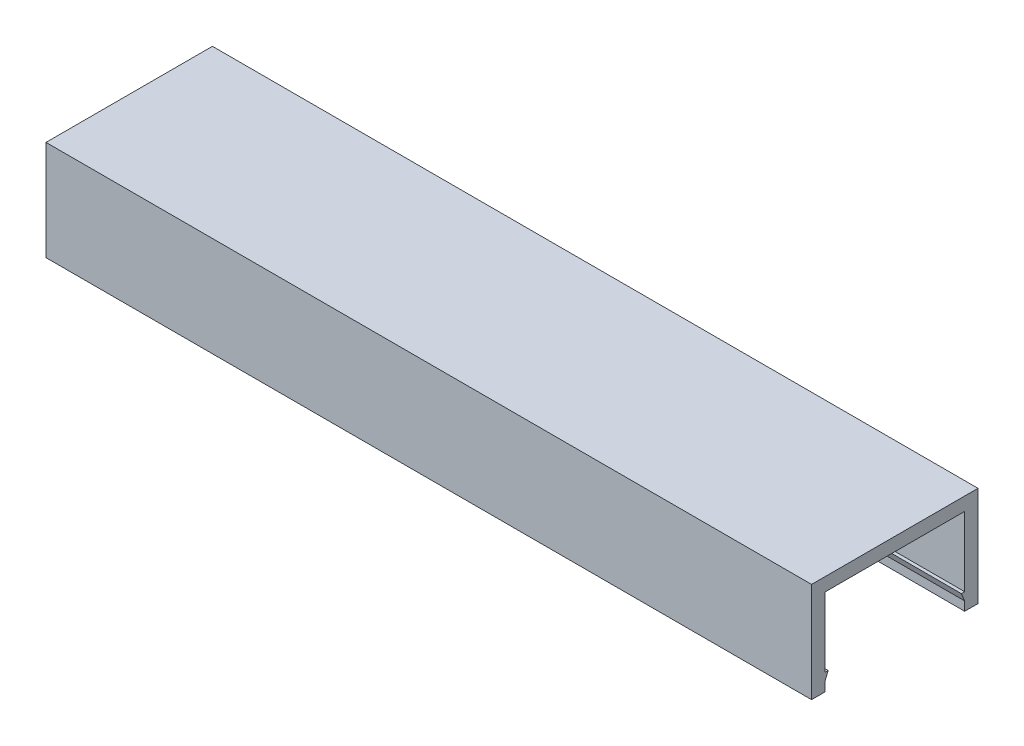
from build123d import *

# Parameters (mm, degrees)
CROQUIS1_W              = 115
CROQUIS1_H              = 20.7
CROQUIS1_H_2            = 2.15
SALIENTE_EXTRUIR1_DEPTH = 15
CROQUIS2_W              = 21
CROQUIS2_H              = 13
CORTAR_EXTRUIR1_DEPTH   = 230
SALIENTE_EXTRUIR4_DEPTH = 115


with BuildPart() as part:
    # Croquis1 → Saliente-Extruir1 (new body)
    with BuildSketch(Plane(origin=(0, 0, 0), x_dir=(1, 0, 0), z_dir=(0, 1, 0))):
        Rectangle(CROQUIS1_W, CROQUIS1_H)
        with Locations((0, 11.425)):
            Rectangle(CROQUIS1_W, CROQUIS1_H_2)
        with Locations((0, -11.425)):
            Rectangle(CROQUIS1_W, CROQUIS1_H_2)
    extrude(amount=SALIENTE_EXTRUIR1_DEPTH)

    # Croquis2 → Cortar-Extruir1 (cut)
    with BuildSketch(Plane.ZY.offset(57.5)):
        with Locations((0, 6.5)):
            Rectangle(CROQUIS2_W, CROQUIS2_H)
    extrude(amount=-CORTAR_EXTRUIR1_DEPTH, mode=Mode.SUBTRACT)

    # Croquis11 → Saliente-Extruir4 (add)
    with BuildSketch(Plane.ZY.offset(57.5)):
        Polygon((-10.5, 1.35), (-10.5, 2.55), (-10, 2.55), align=None)
        Polygon((10, 2.55), (10.5, 1.35), (10.5, 2.55), align=None)
    extrude(amount=-SALIENTE_EXTRUIR4_DEPTH)


solid = part.part
